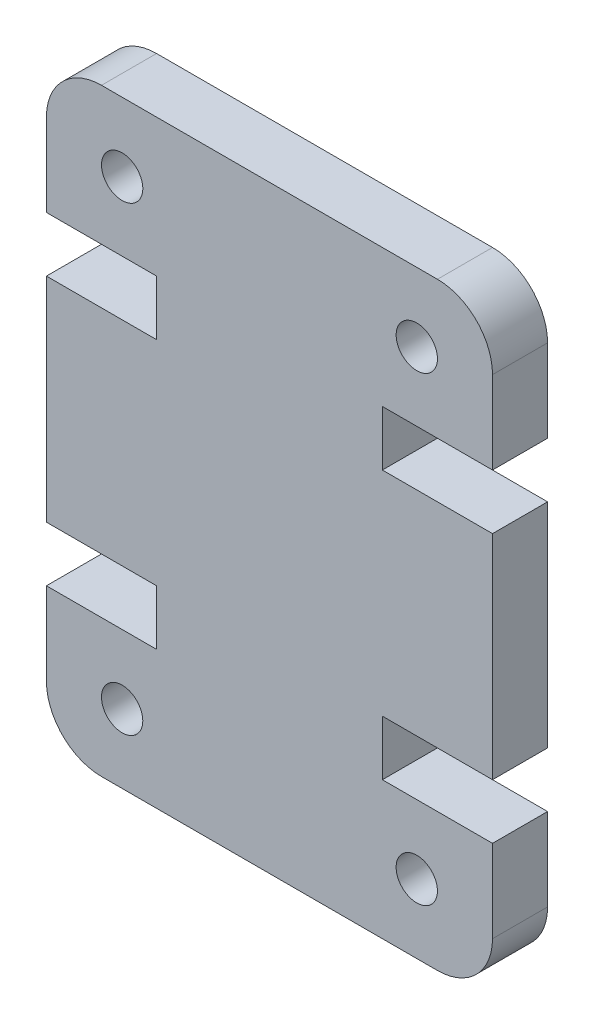
from build123d import *

# Parameters (mm, degrees)
SKETCH1_R           = 0.75
BOSS_EXTRUDE1_DEPTH = 2


with BuildPart() as part:
    # Sketch1 → Boss-Extrude1 (new body)
    with BuildSketch(Plane.XY):
        with BuildLine():
            Line((0, 14.74), (0, 7))
            Line((0, 7), (4, 7))
            Line((4, 7), (4, 5))
            Line((4, 5), (0, 5))
            Line((0, 5), (0, 2))
            ThreePointArc((0, 2), (0.585786438, 0.585786438), (2, 0))
            Line((2, 0), (14.2, 0))
            ThreePointArc((14.2, 0), (15.614213562, 0.585786438), (16.2, 2))
            Line((16.2, 2), (16.2, 5))
            Line((16.2, 5), (12.2, 5))
            Line((12.2, 5), (12.2, 7))
            Line((12.2, 7), (16.2, 7))
            Line((16.2, 7), (16.2, 14.74))
            Line((16.2, 14.74), (12.2, 14.74))
            Line((12.2, 14.74), (12.2, 16.74))
            Line((12.2, 16.74), (16.2, 16.74))
            Line((16.2, 16.74), (16.2, 19.74))
            ThreePointArc((16.2, 19.74), (15.614213562, 21.154213562), (14.2, 21.74))
            Line((14.2, 21.74), (2, 21.74))
            ThreePointArc((2, 21.74), (0.585786438, 21.154213562), (0, 19.74))
            Line((0, 19.74), (0, 16.74))
            Line((0, 16.74), (4, 16.74))
            Line((4, 16.74), (4, 14.74))
            Line((4, 14.74), (0, 14.74))
        make_face()
        with Locations((13.45, 2.5)):
            Circle(SKETCH1_R, mode=Mode.SUBTRACT)
        with Locations((2.75, 19.24)):
            Circle(SKETCH1_R, mode=Mode.SUBTRACT)
        with Locations((2.75, 2.5)):
            Circle(SKETCH1_R, mode=Mode.SUBTRACT)
        with Locations((13.45, 19.24)):
            Circle(SKETCH1_R, mode=Mode.SUBTRACT)
    extrude(amount=BOSS_EXTRUDE1_DEPTH)


solid = part.part
